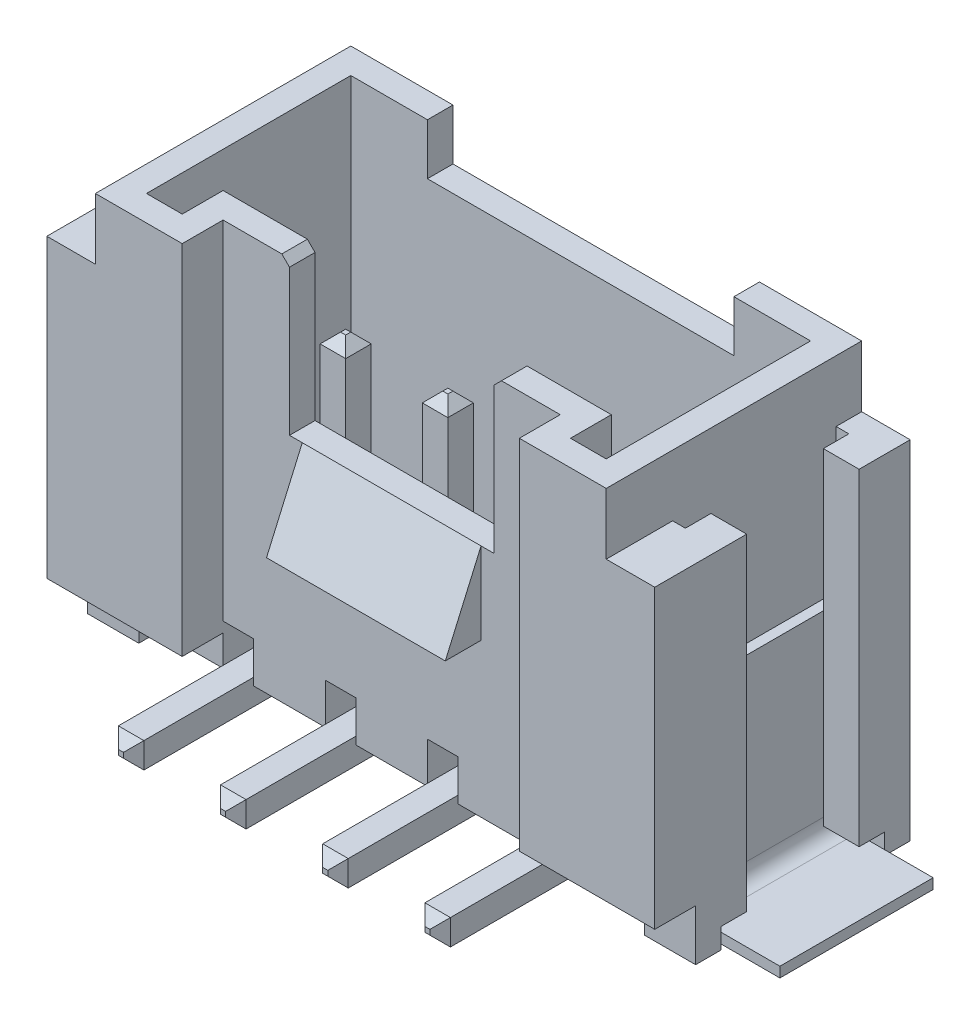
from build123d import *

# Parameters (mm, degrees)
ESQUISSE1_W                             = 10
ESQUISSE1_H                             = 5
BOSS_EXTRU_1_DEPTH                      = 8
ESQUISSE2_W                             = 6.6
ESQUISSE2_H                             = 1.6
ENL_V_MAT_EXTRU_1_DEPTH                 = 9
ENL_V_MAT_EXTRU_2_DEPTH                 = 6.5
BOSS_EXTRU_3_START                      = -1.2
BOSS_EXTRU_3_DEPTH                      = 6.8
ESQUISSE5_W                             = 6
ESQUISSE5_H                             = 1
ENL_V_MAT_EXTRU_3_DEPTH                 = 1
ESQUISSE6_W                             = 4
ESQUISSE6_H                             = 1
ENL_V_MAT_EXTRU_4_DEPTH                 = 3
ESQUISSE7_W                             = 0.8
ESQUISSE7_H                             = 1
ENL_V_MAT_EXTRU_5_DEPTH                 = 12.9
BOSS_EXTRU_2_DEPTH                      = 1.75
ENL_V_MAT_EXTRU_6_DEPTH                 = 5.2
ESQUISSE20_W                            = 3.2
ESQUISSE20_H                            = 0.4
ENL_V_MAT_EXTRU_7_DEPTH                 = 12.2
ENL_V_MAT_EXTRU_7_DEPTH_BACK            = 1.7
CHANFREIN1_SIZE                         = 0.15
EXTRU_MINCE1_DEPTH                      = 0.25
CHANFREIN2_SIZE                         = 0.2
R_P_TITION_LIN_AIRE1_COUNT              = 4
R_P_TITION_LIN_AIRE1_PITCH              = 2
CHANFREIN2_OF_R_P_TITION_LIN_AIRE1_SIZE = 0.2
EXTRU_MINCE2_START                      = 0.1
EXTRU_MINCE2_DEPTH                      = 3


with BuildPart() as part:
    # Esquisse1 → Boss.-Extru.1 (new body)
    with BuildSketch(Plane(origin=(0, 0, 0), x_dir=(1, 0, 0), z_dir=(0, 1, 0))):
        with Locations((0, 2.5)):
            Rectangle(ESQUISSE1_W, ESQUISSE1_H)
    extrude(amount=BOSS_EXTRU_1_DEPTH)

    # Esquisse2 → Enlèv. mat.-Extru.1 (cut, through all)
    with BuildSketch(Plane(origin=(0, 8, 0), x_dir=(1, 0, 0), z_dir=(0, 1, 0))):
        Rectangle(ESQUISSE2_W, ESQUISSE2_H)
    extrude(amount=-ENL_V_MAT_EXTRU_1_DEPTH, mode=Mode.SUBTRACT)

    # Esquisse4 → Enlèv. mat.-Extru.2 (cut)
    with BuildSketch(Plane(origin=(0, 8, 0), x_dir=(1, 0, 0), z_dir=(0, 1, 0))):
        Polygon((-3.8, 1.3), (3.8, 1.3), (3.8, 0.5), (4.5, 0.5), (4.5, 4.5), (-4.5, 4.5), (-4.5, 0.5), (-3.8, 0.5), align=None)
    extrude(amount=-ENL_V_MAT_EXTRU_2_DEPTH, mode=Mode.SUBTRACT)

    # Esquisse17 → Boss.-Extru.3 (add)
    with BuildSketch(Plane(origin=(0, 8, 0), x_dir=(1, 0, 0), z_dir=(0, 1, 0)).offset(BOSS_EXTRU_3_START)):
        Polygon((5.95, 5), (5, 5), (5, 4.5), (5.25, 4.5), (5.25, 4), (5.95, 4), align=None)
        Polygon((5.25, 1.3), (5, 1.3), (5, 0), (5.95, 0), (5.95, 1.8), (5.25, 1.8), align=None)
    boss_extru_3 = extrude(amount=-BOSS_EXTRU_3_DEPTH)

    # Symétrie3: Boss.-Extru.3 across plane
    add(boss_extru_3.mirror(Plane(origin=(0, 0, 0), x_dir=(0, 0, 1), z_dir=(1, 0, 0))))

    # Esquisse5 → Enlèv. mat.-Extru.3 (cut)
    with BuildSketch(Plane(origin=(0, 8, 0), x_dir=(1, 0, 0), z_dir=(0, 1, 0))):
        with Locations((0, 4.5)):
            Rectangle(ESQUISSE5_W, ESQUISSE5_H)
    extrude(amount=-ENL_V_MAT_EXTRU_3_DEPTH, mode=Mode.SUBTRACT)

    # Esquisse6 → Enlèv. mat.-Extru.4 (cut)
    with BuildSketch(Plane(origin=(0, 8, 0), x_dir=(1, 0, 0), z_dir=(0, 1, 0))):
        with Locations((0, 0.8)):
            Rectangle(ESQUISSE6_W, ESQUISSE6_H)
    extrude(amount=-ENL_V_MAT_EXTRU_4_DEPTH, mode=Mode.SUBTRACT)

    # Esquisse7 → Enlèv. mat.-Extru.5 (cut, through all)
    with BuildSketch(Plane(origin=(5.95, 0, 0), x_dir=(0, 0, -1), z_dir=(1, 0, 0))):
        with Locations((0.4, 0.5)):
            Rectangle(ESQUISSE7_W, ESQUISSE7_H)
    extrude(amount=-ENL_V_MAT_EXTRU_5_DEPTH, mode=Mode.SUBTRACT)

    # Esquisse11 → Boss.-Extru.2 (add, symmetric)
    with BuildSketch(Plane(origin=(0, 0, 0), x_dir=(0, 0, -1), z_dir=(1, 0, 0))):
        Polygon((0.8, 5), (0.1, 3.4), (0.8, 3.4), align=None)
    extrude(amount=BOSS_EXTRU_2_DEPTH, both=True)

    # Esquisse18 → Enlèv. mat.-Extru.6 (cut, through all)
    with BuildSketch(Plane.XY.offset(-0.8)):
        Polygon((-4.95, 0.4), (-4.95, -0.4), (4.95, -0.4), (4.95, 0.4), (3.3, 0.4), (3.3, 1.2), (2.7, 1.2), (2.7, 0.4), (1.3, 0.4), (1.3, 1.2), (0.7, 1.2), (0.7, 0.4), (-0.7, 0.4), (-0.7, 1.2), (-1.3, 1.2), (-1.3, 0.4), (-2.7, 0.4), (-2.7, 1.2), (-3.3, 1.2), (-3.3, 0.4), align=None)
    extrude(amount=-ENL_V_MAT_EXTRU_6_DEPTH, mode=Mode.SUBTRACT)

    # Esquisse20 → Enlèv. mat.-Extru.7 (cut, two sides)
    with BuildSketch(Plane.ZY.offset(-5.25)) as enl_v_mat_extru_7_sk:
        with Locations((-2.9, 0.2)):
            Rectangle(ESQUISSE20_W, ESQUISSE20_H)
    extrude(amount=ENL_V_MAT_EXTRU_7_DEPTH, mode=Mode.SUBTRACT)
    extrude(enl_v_mat_extru_7_sk.sketch, amount=-ENL_V_MAT_EXTRU_7_DEPTH_BACK, mode=Mode.SUBTRACT)

    # Chanfrein1
    chanfrein1_edges = [part.edges().sort_by_distance(p)[0] for p in [
        (2, 8, -1.05),
        (-2, 8, -1.05),
    ]]
    chamfer(chanfrein1_edges, length=CHANFREIN1_SIZE)


with BuildPart() as body_2:
    # Esquisse21 → Extru.-Mince1 (new body, symmetric)
    with BuildSketch(Plane(origin=(3, 0, 0), x_dir=(0, 0, -1), z_dir=(1, 0, 0))):
        with BuildLine():
            Line((2.65, 5.2), (2.65, 0.75))
            ThreePointArc((2.65, 0.75), (2.576776695, 0.573223305), (2.4, 0.5))
            Line((2.4, 0.5), (-1.5, 0.5))
            Line((-1.5, 0.5), (-1.5, 0))
            Line((-1.5, 0), (2.4, 0))
            ThreePointArc((2.4, 0), (2.930330086, 0.219669914), (3.15, 0.75))
            Line((3.15, 0.75), (3.15, 5.2))
            Line((3.15, 5.2), (2.65, 5.2))
        make_face()
    extru_mince1 = extrude(amount=EXTRU_MINCE1_DEPTH, both=True)

    # Chanfrein2
    chanfrein2_edges = [body_2.edges().sort_by_distance(p)[0] for p in [
        (3, 5.2, -2.65),
        (3, 5.2, -3.15),
        (3, 0, 1.5),
        (3, 0.5, 1.5),
        (3.25, 5.2, -2.9),
        (3.25, 0.25, 1.5),
        (2.75, 5.2, -2.9),
        (2.75, 0.25, 1.5),
    ]]
    chamfer(chanfrein2_edges, length=CHANFREIN2_SIZE)


with BuildPart() as part_1:
    add(part.part)

    # Répétition linéaire1: Extru.-Mince1 ×4
    with Locations(*[(-i * R_P_TITION_LIN_AIRE1_PITCH, 0, 0) for i in range(1, R_P_TITION_LIN_AIRE1_COUNT)]):
        add(extru_mince1)

    # Chanfrein2 of Répétition linéaire1
    chanfrein2_of_r_p_tition_lin_aire1_edges = [part_1.edges().sort_by_distance(p)[0] for p in [
        (1, 5.2, -2.65),
        (1, 5.2, -3.15),
        (1, 0, 1.5),
        (1, 0.5, 1.5),
        (1.25, 5.2, -2.9),
        (1.25, 0.25, 1.5),
        (0.75, 5.2, -2.9),
        (0.75, 0.25, 1.5),
        (-1, 5.2, -2.65),
        (-1, 5.2, -3.15),
        (-1, 0, 1.5),
        (-1, 0.5, 1.5),
        (-0.75, 5.2, -2.9),
        (-0.75, 0.25, 1.5),
        (-1.25, 5.2, -2.9),
        (-1.25, 0.25, 1.5),
        (-3, 5.2, -2.65),
        (-3, 5.2, -3.15),
        (-3, 0, 1.5),
        (-3, 0.5, 1.5),
        (-2.75, 5.2, -2.9),
        (-2.75, 0.25, 1.5),
        (-3.25, 5.2, -2.9),
        (-3.25, 0.25, 1.5),
    ]]
    chamfer(chanfrein2_of_r_p_tition_lin_aire1_edges, length=CHANFREIN2_OF_R_P_TITION_LIN_AIRE1_SIZE)


with BuildPart() as body_3:
    # Esquisse22 → Extru.-Mince2 (new body)
    with BuildSketch(Plane(origin=(0, 0, -1.3), x_dir=(-1, 0, 0), z_dir=(0, 0, -1)).offset(EXTRU_MINCE2_START)):
        with BuildLine():
            Line((-5, 4), (-5, 0.5))
            ThreePointArc((-5, 0.5), (-5.146446609, 0.146446609), (-5.5, 0))
            Line((-5.5, 0), (-7, 0))
            Line((-7, 0), (-7, 0.2))
            Line((-7, 0.2), (-5.5, 0.2))
            ThreePointArc((-5.5, 0.2), (-5.287867966, 0.287867966), (-5.2, 0.5))
            Line((-5.2, 0.5), (-5.2, 4))
            Line((-5.2, 4), (-5, 4))
        make_face()
    extrude(amount=EXTRU_MINCE2_DEPTH)


with BuildPart() as body_4:
    # Symétrie4: mirrored copy
    add(body_3.part.mirror(Plane(origin=(0, 0, 0), x_dir=(0, 0, 1), z_dir=(1, 0, 0))))


solid = Compound([body_2.part, part_1.part, body_3.part, body_4.part])
